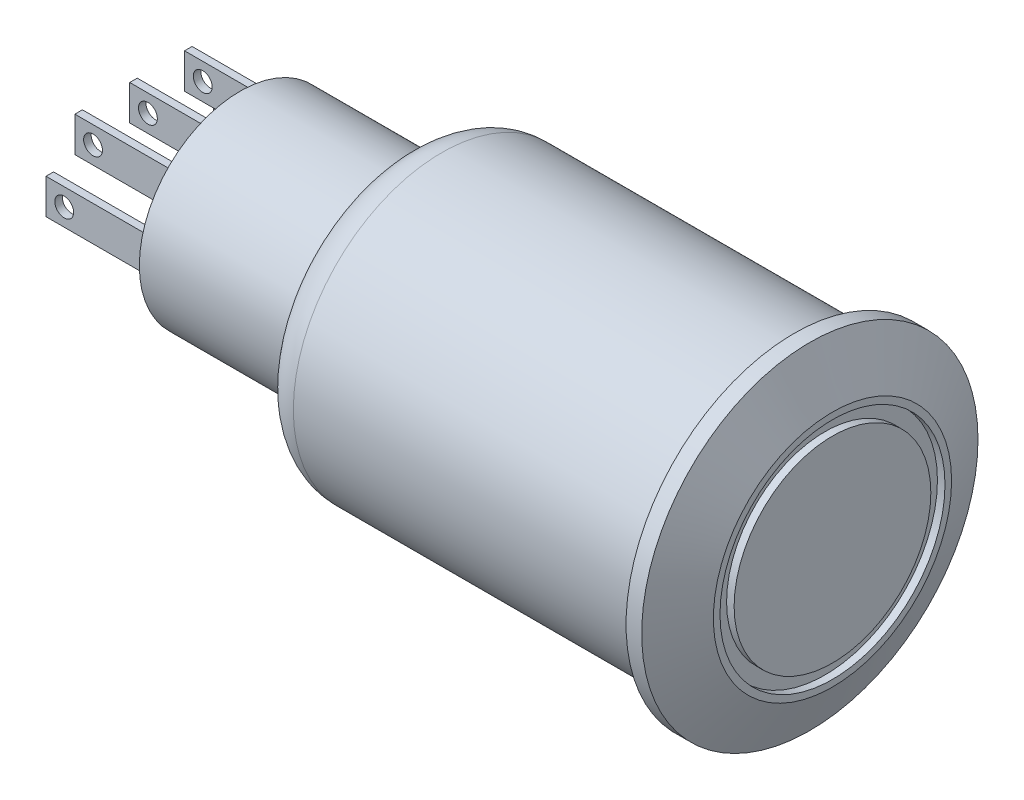
from build123d import *

# Parameters (mm, degrees)
SKETCH1_R           = 7.875
BOSS_EXTRUDE1_DEPTH = 20.68
SKETCH2_R           = 8.915
BOSS_EXTRUDE2_DEPTH = 2.03
SKETCH3_R           = 5.965
SKETCH3_R_2         = 5.215
CUT_EXTRUDE1_DEPTH  = 0.4
CHAMFER1_SIZE       = 1.2
CHAMFER1_SIZE2      = 2.6
SKETCH4_R           = 5.34
BOSS_EXTRUDE3_DEPTH = 8.7
SKETCH5_W           = 0.4
SKETCH5_H           = 1.86
BOSS_EXTRUDE4_DEPTH = 5.65
SKETCH6_R           = 0.5
CUT_EXTRUDE2_DEPTH  = 14.552865697
FILLET1_R           = 2


with BuildPart() as part:
    # Sketch1 → Boss-Extrude1 (new body)
    with BuildSketch(Plane(origin=(0, 0, 0), x_dir=(0, 0, -1), z_dir=(1, 0, 0))):
        Circle(SKETCH1_R)
    extrude(amount=BOSS_EXTRUDE1_DEPTH)

    # Sketch2 → Boss-Extrude2 (add)
    with BuildSketch(Plane(origin=(20.68, 0, 0), x_dir=(0, 0, -1), z_dir=(1, 0, 0))):
        Circle(SKETCH2_R)
    extrude(amount=BOSS_EXTRUDE2_DEPTH)

    # Sketch3 → Cut-Extrude1 (cut)
    with BuildSketch(Plane(origin=(22.71, 0, 0), x_dir=(0, 0, -1), z_dir=(1, 0, 0))):
        Circle(SKETCH3_R)
        Circle(SKETCH3_R_2, mode=Mode.SUBTRACT)
    extrude(amount=-CUT_EXTRUDE1_DEPTH, mode=Mode.SUBTRACT)

    # Chamfer1
    chamfer1_edges = [part.edges().sort_by_distance(p)[0] for p in [
        (22.71, 0, 8.915),
    ]]
    chamfer1_side = [part.faces().sort_by_distance(p)[0] for p in [
        (21.695, 0, 8.915),
    ]]
    chamfer(chamfer1_edges, length=CHAMFER1_SIZE, length2=CHAMFER1_SIZE2, reference=chamfer1_side[0])

    # Sketch4 → Boss-Extrude3 (add)
    with BuildSketch(Plane.ZY):
        Circle(SKETCH4_R)
    extrude(amount=BOSS_EXTRUDE3_DEPTH)

    # Sketch5 → Boss-Extrude4 (add)
    with BuildSketch(Plane.ZY.offset(8.7)):
        with Locations((-2.90816811, 2.08596309)):
            Rectangle(SKETCH5_W, SKETCH5_H)
        with Locations((0, 2.08596309)):
            Rectangle(SKETCH5_W, SKETCH5_H)
        with Locations((2.90816811, 2.08596309)):
            Rectangle(SKETCH5_W, SKETCH5_H)
        with Locations((4.437865697, 0)):
            Rectangle(SKETCH5_W, SKETCH5_H)
        with Locations((-4.437865697, 0)):
            Rectangle(SKETCH5_W, SKETCH5_H)
    extrude(amount=BOSS_EXTRUDE4_DEPTH)

    # Sketch6 → Cut-Extrude2 (cut, through all)
    with BuildSketch(Plane(origin=(0, 0, -4.637865697), x_dir=(-1, 0, 0), z_dir=(0, 0, -1))):
        with Locations((13.385032673, 0)):
            Circle(SKETCH6_R)
        with Locations((13.385032673, 2.08596309)):
            Circle(SKETCH6_R)
    extrude(amount=-CUT_EXTRUDE2_DEPTH, mode=Mode.SUBTRACT)

    # Fillet1
    fillet1_edges = [part.edges().sort_by_distance(p)[0] for p in [
        (0, 0, 7.875),
    ]]
    fillet(fillet1_edges, radius=FILLET1_R)


solid = part.part
